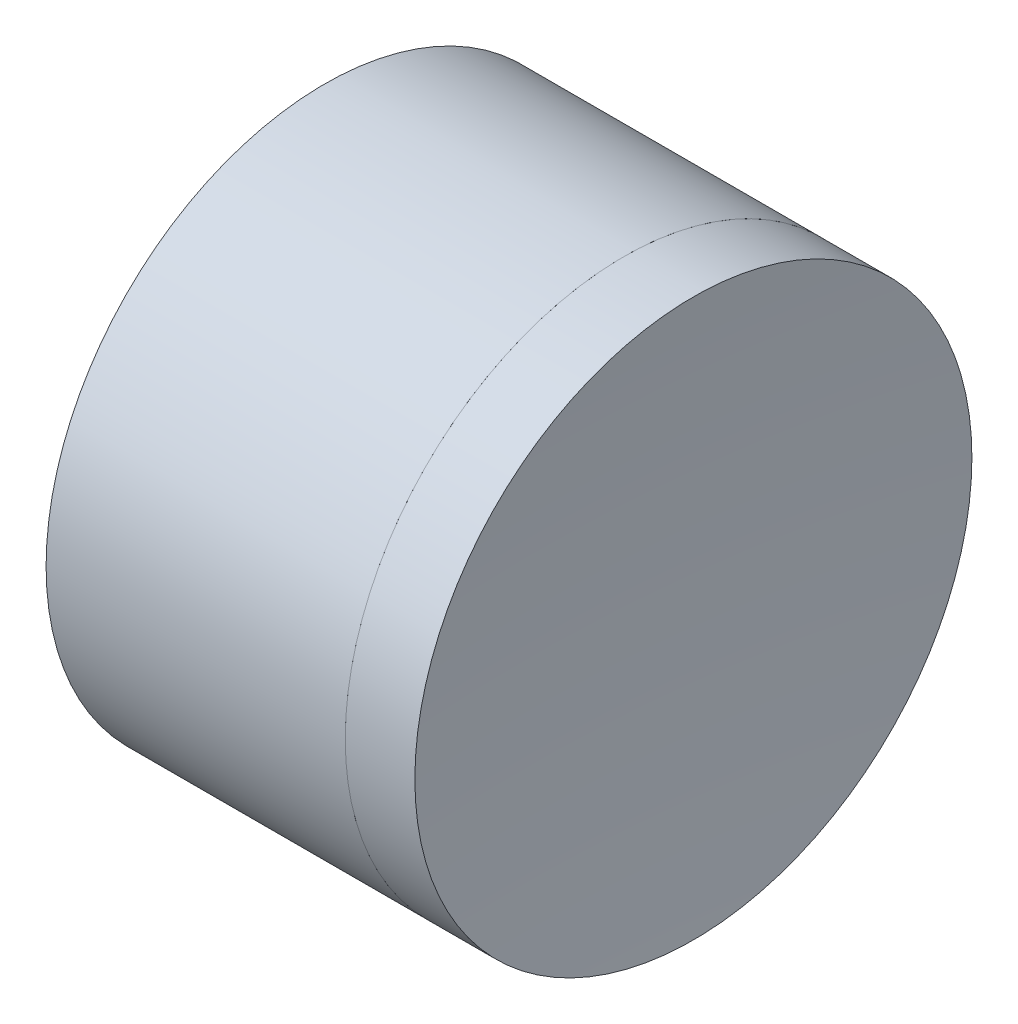
from build123d import *


with BuildPart() as part:
    # 草图1 one side → 旋转1 (revolve)
    with BuildSketch(Plane(origin=(0, 0, 0), x_dir=(1, 0, 0), z_dir=(0, 1, 0)), mode=Mode.PRIVATE) as revolve_1_sk:
        with BuildLine():
            Line((240.290058537, 12.5), (226.864350004, 12.5))
            ThreePointArc((226.864350004, 12.5), (229.889546757, 6.572599397), (230.932058369, 0))
            Line((230.932058369, 0), (234.932058369, 0))
            ThreePointArc((234.932058369, 0), (236.328009121, 6.799966283), (240.290058537, 12.5))
        make_face()
    revolve(revolve_1_sk.sketch.rotate(Axis((-0.816062176, 0, 0), (1, 0, 0)), 180), axis=Axis((-0.816062176, 0, 0), (1, 0, 0)))  # turned: the seam where the file's is


with BuildPart() as body_2:
    # 草图2 one side → 旋转3 (revolve)
    with BuildSketch(Plane(origin=(0, 0, 0), x_dir=(1, 0, 0), z_dir=(0, 1, 0)), mode=Mode.PRIVATE) as revolve_3_sk:
        with BuildLine():
            Line((243.414314814, 12.5), (240.290058537, 12.5))
            ThreePointArc((240.290058537, 12.5), (236.328009121, 6.799966283), (234.932058369, 0))
            Line((234.932058369, 0), (242.932058369, 0))
            ThreePointArc((242.932058369, 0), (243.05266731, 6.254649696), (243.414314814, 12.5))
        make_face()
    revolve(revolve_3_sk.sketch.rotate(Axis((226.864350004, 0, 0), (1, 0, 0)), 180), axis=Axis((226.864350004, 0, 0), (1, 0, 0)))  # turned: the seam where the file's is


solid = Compound([part.part, body_2.part])
